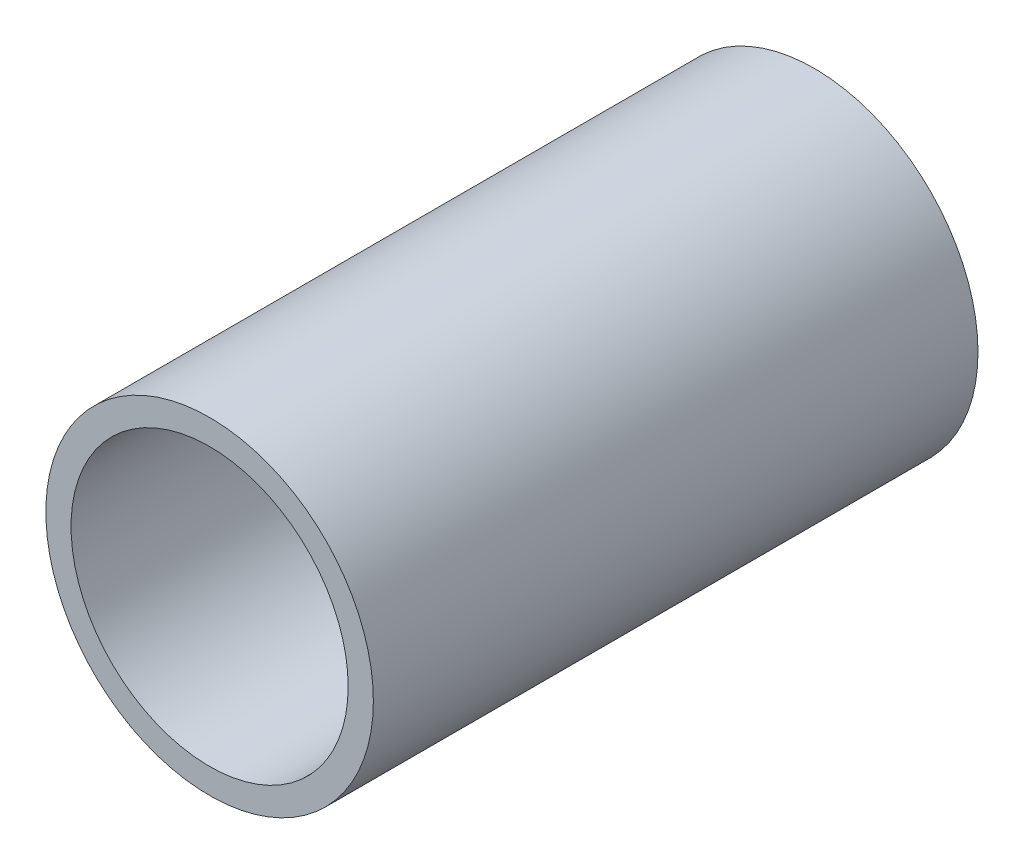
from build123d import *

# Parameters (mm, degrees)
SKETCH1_R           = 3.25
BOSS_EXTRUDE1_DEPTH = 12
SKETCH4_R           = 2.75
CUT_EXTRUDE3_DEPTH  = 12


with BuildPart() as part:
    # Sketch1 → Boss-Extrude1 (new body)
    with BuildSketch(Plane.XY):
        Circle(SKETCH1_R)
    extrude(amount=BOSS_EXTRUDE1_DEPTH)

    # Sketch4 → Cut-Extrude3 (cut)
    with BuildSketch(Plane.XY.offset(12)):
        Circle(SKETCH4_R)
    extrude(amount=-CUT_EXTRUDE3_DEPTH, mode=Mode.SUBTRACT)


solid = part.part
